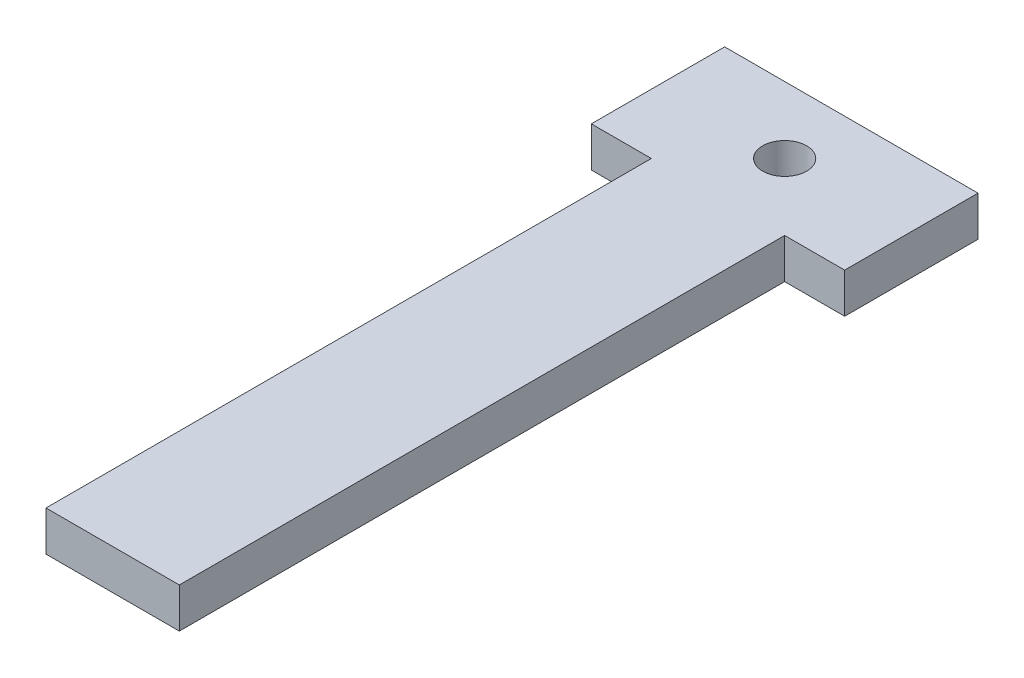
from build123d import *

# Parameters (mm, degrees)
SKETCH1_W           = 10
SKETCH1_H           = 55.4
SKETCH1_R           = 1.65
SKETCH1_W_2         = 4.5
SKETCH1_H_2         = 10
BOSS_EXTRUDE1_DEPTH = 3


with BuildPart() as part:
    # Sketch1 → Boss-Extrude1 (new body)
    with BuildSketch(Plane(origin=(0, 0, 0), x_dir=(1, 0, 0), z_dir=(0, 1, 0))):
        with Locations((0, -22.7)):
            Rectangle(SKETCH1_W, SKETCH1_H)
        Circle(SKETCH1_R, mode=Mode.SUBTRACT)
        with Locations((-7.25, 0)):
            Rectangle(SKETCH1_W_2, SKETCH1_H_2)
        with Locations((7.25, 0)):
            Rectangle(SKETCH1_W_2, SKETCH1_H_2)
    extrude(amount=BOSS_EXTRUDE1_DEPTH)


solid = part.part
